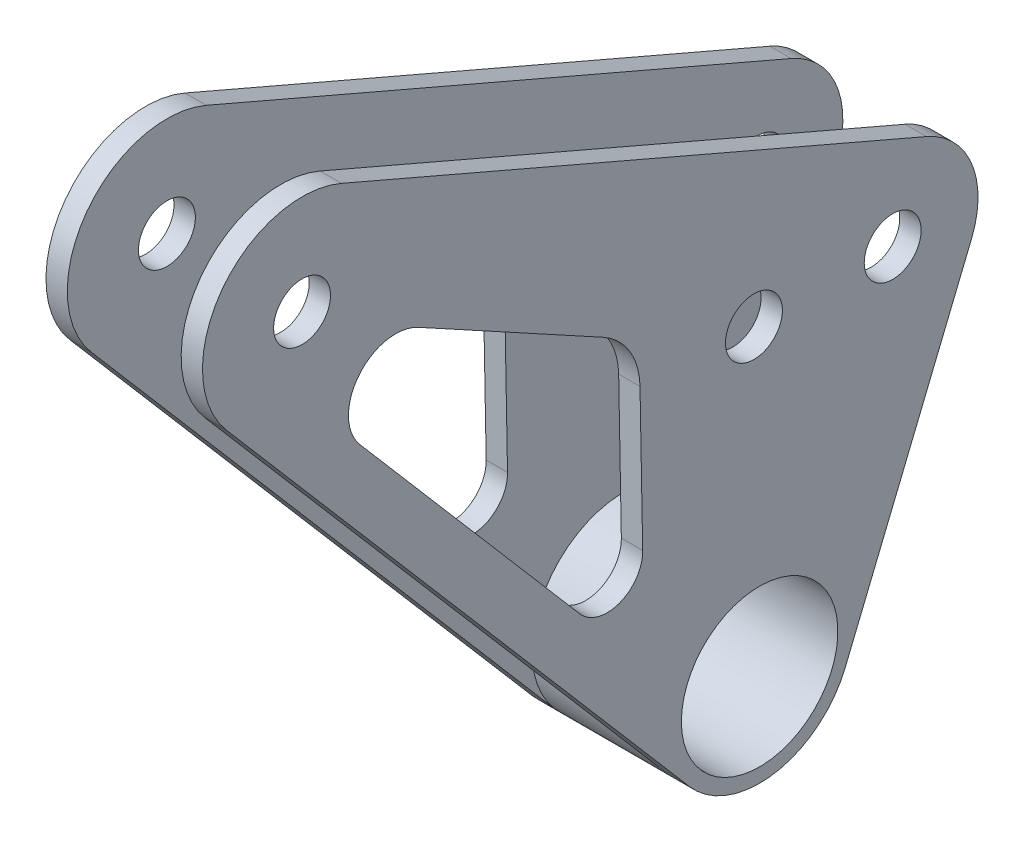
from build123d import *
from build123d.topology import SkipClean

# Parameters (mm, degrees)
SKETCH1_R               = 4
SKETCH1_R_2             = 11
BOSS_EXTRUDE2_DEPTH     = 11
SKETCH1_8_R             = 4
CUT_EXTRUDE1_DEPTH      = 8
CUT_EXTRUDE2_DEPTH      = 465.250893914
CUT_EXTRUDE2_DEPTH_BACK = 465.250893914
SKETCH6_R               = 4
BOSS_EXTRUDE8_DEPTH     = 11
SKETCH6_6_R             = 4
CUT_EXTRUDE3_DEPTH      = 8


with BuildPart() as part:
    # Sketch1 → Boss-Extrude2 (new, symmetric)
    with BuildSketch(Plane.ZY.offset(-709.53)):
        with BuildLine():
            Line((193.569972926, 283.579288774), (258.649201612, 359.498464834))
            ThreePointArc((258.649201612, 359.498464834), (258.8956606, 377.425895105), (241.305287216, 380.894650269))
            Line((241.305287216, 380.894650269), (178.264909558, 346.43717525))
            ThreePointArc((178.264909558, 346.43717525), (173.380579242, 341.764870601), (171.502250327, 335.271874849))
            Line((171.502250327, 335.271874849), (170.702250327, 292.281874849))
            ThreePointArc((170.702250327, 292.281874849), (179.076203082, 279.89008222), (193.569972926, 283.579288774))
        make_face()
        with Locations((248.02, 368.61)):
            Circle(SKETCH1_R, mode=Mode.SUBTRACT)
        with Locations((183.7, 292.04)):
            Circle(SKETCH1_R_2, mode=Mode.SUBTRACT)
        with Locations((184.5, 335.03)):
            Circle(SKETCH1_R, mode=Mode.SUBTRACT)
    extrude(amount=BOSS_EXTRUDE2_DEPTH, both=True)

    # Sketch1_8 → Cut-Extrude1 (cut, symmetric)
    with SkipClean():  # the faces are left unmerged after this step: merging them gives an invalid solid
        with BuildSketch(Plane.ZY.offset(-709.53)):
            with BuildLine():
                Line((193.569972926, 283.579288774), (258.649201612, 359.498464834))
                ThreePointArc((258.649201612, 359.498464834), (258.8956606, 377.425895105), (241.305287216, 380.894650269))
                Line((241.305287216, 380.894650269), (178.264909558, 346.43717525))
                ThreePointArc((178.264909558, 346.43717525), (173.380579242, 341.764870601), (171.502250327, 335.271874849))
                Line((171.502250327, 335.271874849), (170.702250327, 292.281874849))
                ThreePointArc((170.702250327, 292.281874849), (188.323796918, 304.18991778), (193.569972926, 283.579288774))
            make_face()
            with Locations((248.02, 368.61)):
                Circle(SKETCH1_8_R, mode=Mode.SUBTRACT)
            with Locations((184.5, 335.03)):
                Circle(SKETCH1_8_R, mode=Mode.SUBTRACT)
        extrude(amount=CUT_EXTRUDE1_DEPTH, both=True, mode=Mode.SUBTRACT)

    # Sketch5 → Cut-Extrude2 (cut, two sides: drawn at the far end of the back side and taken through both)
    with SkipClean():  # the faces are left unmerged after this step: merging them gives an invalid solid
        with BuildSketch(Plane.ZY.offset(-698.53).offset(-CUT_EXTRUDE2_DEPTH_BACK)):
            with BuildLine():
                ThreePointArc((239.094141672, 357.824405296), (235.493117639, 359.319123456), (231.673739179, 358.535602781))
                Line((231.673739179, 358.535602781), (205.718398062, 344.348576127))
                ThreePointArc((205.718398062, 344.348576127), (201.961220896, 340.754495628), (200.5163525, 335.75988351))
                Line((200.5163525, 335.75988351), (200.141351056, 315.608243405))
                ThreePointArc((200.141351056, 315.608243405), (203.362102115, 310.842169317), (208.936628978, 312.261094915))
                Line((208.936628978, 312.261094915), (239.902269766, 348.384539863))
                ThreePointArc((239.902269766, 348.384539863), (241.477282786, 353.273897429), (239.094141672, 357.824405296))
            make_face()
        extrude(amount=CUT_EXTRUDE2_DEPTH + CUT_EXTRUDE2_DEPTH_BACK, mode=Mode.SUBTRACT)

    # Sketch6 → Boss-Extrude8 (add, symmetric)
    with BuildSketch(Plane.ZY.offset(-709.53)):
        with BuildLine():
            ThreePointArc((160.253054899, 346.051184701), (153.890022283, 339.565239259), (153.896376335, 330.479226273))
            Line((153.896376335, 330.479226273), (171.671074363, 287.109995129))
            ThreePointArc((171.671074363, 287.109995129), (170.922257468, 289.64640526), (170.702250327, 292.281874849))
            Line((170.702250327, 292.281874849), (171.502250327, 335.271874849))
            ThreePointArc((171.502250327, 335.271874849), (173.380579242, 341.764870601), (178.264909558, 346.43717525))
            Line((178.264909558, 346.43717525), (241.305287216, 380.894650269))
            ThreePointArc((241.305287216, 380.894650269), (241.886887594, 381.195107557), (242.481897383, 381.468048818))
            Line((242.481897383, 381.468048818), (160.253054899, 346.051184701))
        make_face()
        with Locations((165, 335.03)):
            Circle(SKETCH6_R, mode=Mode.SUBTRACT)
    extrude(amount=BOSS_EXTRUDE8_DEPTH, both=True)

    # Sketch6_6 → Cut-Extrude3 (cut, symmetric)
    with SkipClean():  # the faces are left unmerged after this step: merging them gives an invalid solid
        with BuildSketch(Plane.ZY.offset(-709.53)):
            with BuildLine():
                ThreePointArc((160.253054899, 346.051184701), (153.890022283, 339.565239259), (153.896376335, 330.479226273))
                Line((153.896376335, 330.479226273), (171.671074363, 287.109995129))
                ThreePointArc((171.671074363, 287.109995129), (170.922257468, 289.64640526), (170.702250327, 292.281874849))
                Line((170.702250327, 292.281874849), (171.502250327, 335.271874849))
                ThreePointArc((171.502250327, 335.271874849), (173.380579242, 341.764870601), (178.264909558, 346.43717525))
                Line((178.264909558, 346.43717525), (241.305287216, 380.894650269))
                ThreePointArc((241.305287216, 380.894650269), (241.886887594, 381.195107557), (242.481897383, 381.468048818))
                Line((242.481897383, 381.468048818), (160.253054899, 346.051184701))
            make_face()
            with Locations((165, 335.03)):
                Circle(SKETCH6_6_R, mode=Mode.SUBTRACT)
        extrude(amount=CUT_EXTRUDE3_DEPTH, both=True, mode=Mode.SUBTRACT)


solid = part.part
